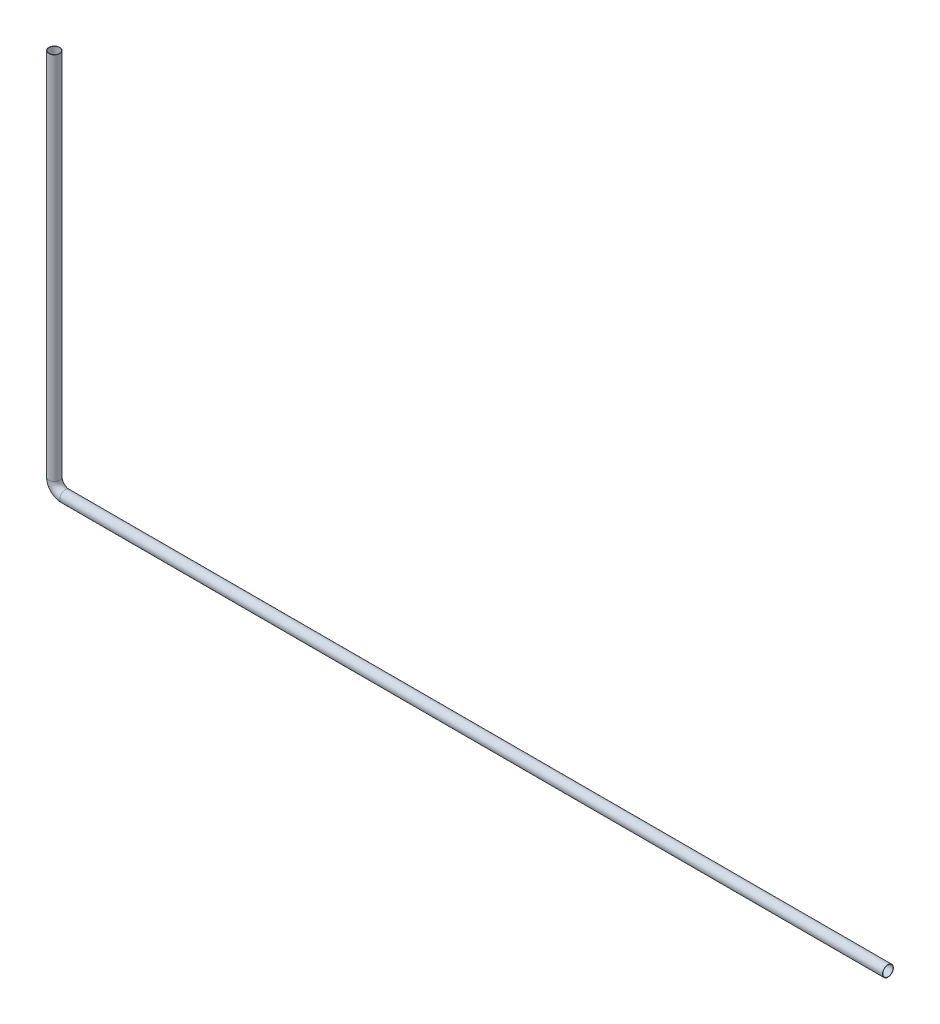
from build123d import *

# Parameters (mm, degrees)
SWEEP_THIN1_PROFILE_R   = 15
SWEEP_THIN1_PROFILE_R_2 = 14


with BuildPart() as part:
    # Sweep-Thin1: sweep along a curve in space
    with BuildLine() as sweep_thin1_path:
        Line((-34220.216064675, -16256.702563295, 40211.577712625), (-34220.216064675, -17268.210932222, 40211.577712625))
        ThreePointArc((-34190.216064675, -17298.210932222, 40211.577712625), (-34211.429268111, -17289.424135658, 40211.577712625), (-34220.216064675, -17268.210932222, 40211.577712625))
        Line((-34190.216064675, -17298.210932222, 40211.577712625), (-31937.449283249, -17298.210932222, 40211.577712625))
    # Sweep-Thin1 profile (on start of the path) → Sweep-Thin1 (sweep)
    with BuildSketch(Plane(origin=(-34220.216064675, -16256.702563295, 40211.577712625), x_dir=(0, 0, -1), z_dir=(0, -1, 0))):
        Circle(SWEEP_THIN1_PROFILE_R)
        Circle(SWEEP_THIN1_PROFILE_R_2, mode=Mode.SUBTRACT)
    sweep(path=sweep_thin1_path.line)


solid = part.part
